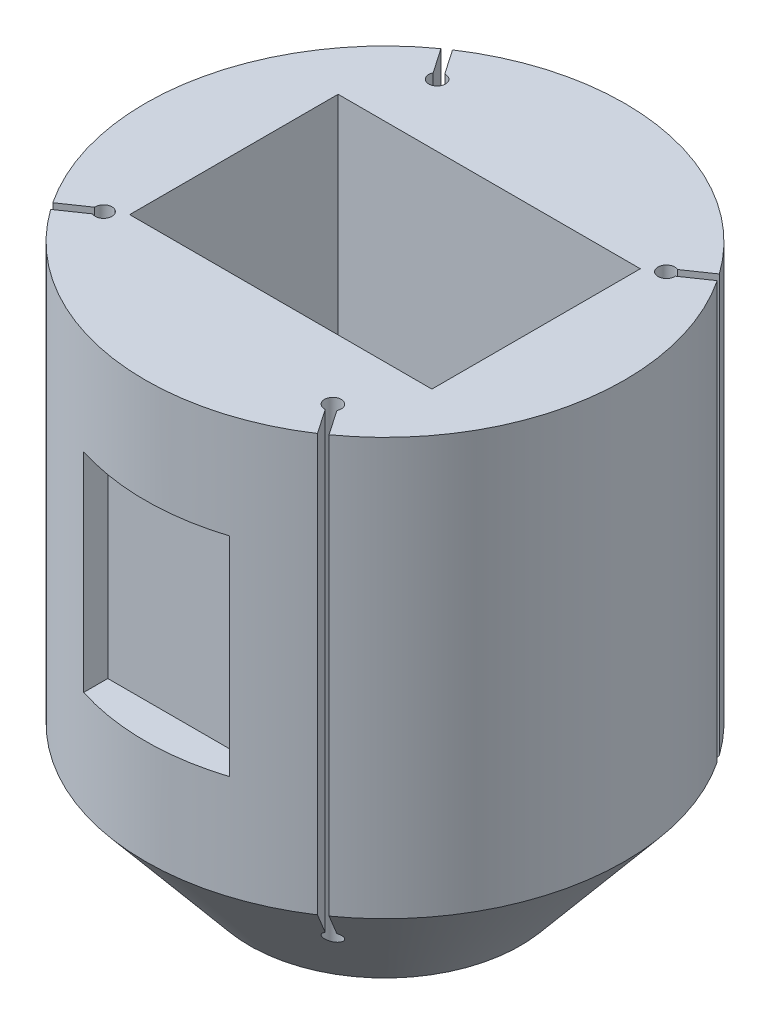
from build123d import *

# Parameters (mm, degrees)
TAGLIO_ESTRUSIONE1_REACH = 262
SCHIZZO3_W               = 145
SCHIZZO3_H               = 100
TAGLIO_ESTRUSIONE2_DEPTH = 100
SCHIZZO4_R               = 4
TAGLIO_ESTRUSIONE3_DEPTH = 250
SCHIZZO6_W               = 70
SCHIZZO6_H               = 100
TAGLIO_ESTRUSIONE4_DEPTH = 18.0000001


with BuildPart() as part:
    # Schizzo1 → Rivoluzione1 (revolve)
    with BuildSketch(Plane.XY, mode=Mode.PRIVATE) as rivoluzione1_sk:
        Polygon((-21.082480081, 47.728392405), (93.917519919, 47.728392405), (93.917519919, -152.271607595), (43.917519919, -212.271607595), (-21.082480081, -212.271607595), align=None)
    revolve(rivoluzione1_sk.sketch.rotate(Axis((-21.082480081, 47.728392405, 0), (0, -1, 0)), 180), axis=Axis((-21.082480081, 47.728392405, 0), (0, -1, 0)))  # turned: the seam where the file's is

    # Taglio-Estrusione1: up to this cone (the profile starts inside it)
    taglio_estrusione1_end = Plane(origin=(-21.082480081, 47.728392, 0), z_dir=(0, 1, 0)).offset(-337.999998595) * Cone(1e-06, 735.13888827, 882.166664924, align=(Align.CENTER, Align.CENTER, Align.MIN), mode=Mode.PRIVATE)
    # Schizzo2 → Taglio-Estrusione1 (cut, up to the surface)
    with BuildSketch(Plane(origin=(0, 47.728392405, 0), x_dir=(1, 0, 0), z_dir=(0, 1, 0)), mode=Mode.PRIVATE) as taglio_estrusione1_sk1:
        with BuildLine():
            Line((60.639027234, 58.610597259), (72.534951309, 66.78904506))
            ThreePointArc((72.534951309, 66.78904506), (73.682341202, 65.150814632), (74.8010666, 63.492877363))
            Line((74.8010666, 63.492877363), (62.905142526, 55.314429562))
            ThreePointArc((62.905142526, 55.314429562), (55.621352222, 52.733884708), (60.639027234, 58.610597259))
        make_face()
    taglio_estrusione1_tool1 = extrude(taglio_estrusione1_sk1.sketch, amount=-TAGLIO_ESTRUSIONE1_REACH, mode=Mode.PRIVATE) & taglio_estrusione1_end
    add(taglio_estrusione1_tool1.solids().sort_by_distance((63.650663, 47.728392, -58.254036))[0], mode=Mode.SUBTRACT)
    # Schizzo2 → Taglio-Estrusione1 (cut, up to the surface)
    with BuildSketch(Plane(origin=(0, 47.728392405, 0), x_dir=(1, 0, 0), z_dir=(0, 1, 0)), mode=Mode.PRIVATE) as taglio_estrusione1_sk2:
        with BuildLine():
            Line((37.528117178, -81.721507315), (45.706564979, -93.617431389))
            ThreePointArc((45.706564979, -93.617431389), (44.068334551, -94.764821283), (42.410397283, -95.883546681))
            Line((42.410397283, -95.883546681), (34.231949481, -83.987622606))
            ThreePointArc((34.231949481, -83.987622606), (31.651404628, -76.703832303), (37.528117178, -81.721507315))
        make_face()
    taglio_estrusione1_tool2 = extrude(taglio_estrusione1_sk2.sketch, amount=-TAGLIO_ESTRUSIONE1_REACH, mode=Mode.PRIVATE) & taglio_estrusione1_end
    add(taglio_estrusione1_tool2.solids().sort_by_distance((37.171556, 47.728392, 84.733143))[0], mode=Mode.SUBTRACT)
    # Schizzo2 → Taglio-Estrusione1 (cut, up to the surface)
    with BuildSketch(Plane(origin=(0, 47.728392405, 0), x_dir=(1, 0, 0), z_dir=(0, 1, 0)), mode=Mode.PRIVATE) as taglio_estrusione1_sk3:
        with BuildLine():
            Line((-102.803987396, -58.610597259), (-114.69991147, -66.78904506))
            ThreePointArc((-114.69991147, -66.78904506), (-115.847301364, -65.150814632), (-116.966026762, -63.492877363))
            Line((-116.966026762, -63.492877363), (-105.070102687, -55.314429562))
            ThreePointArc((-105.070102687, -55.314429562), (-97.786312384, -52.733884708), (-102.803987396, -58.610597259))
        make_face()
    taglio_estrusione1_tool3 = extrude(taglio_estrusione1_sk3.sketch, amount=-TAGLIO_ESTRUSIONE1_REACH, mode=Mode.PRIVATE) & taglio_estrusione1_end
    add(taglio_estrusione1_tool3.solids().sort_by_distance((-105.815623, 47.728392, 58.254036))[0], mode=Mode.SUBTRACT)
    # Schizzo2 → Taglio-Estrusione1 (cut, up to the surface)
    with BuildSketch(Plane(origin=(0, 47.728392405, 0), x_dir=(1, 0, 0), z_dir=(0, 1, 0)), mode=Mode.PRIVATE) as taglio_estrusione1_sk4:
        with BuildLine():
            Line((-79.69307734, 81.721507315), (-87.871525141, 93.617431389))
            ThreePointArc((-87.871525141, 93.617431389), (-86.233294713, 94.764821283), (-84.575357444, 95.883546681))
            Line((-84.575357444, 95.883546681), (-76.396909643, 83.987622606))
            ThreePointArc((-76.396909643, 83.987622606), (-73.816364789, 76.703832303), (-79.69307734, 81.721507315))
        make_face()
    taglio_estrusione1_tool4 = extrude(taglio_estrusione1_sk4.sketch, amount=-TAGLIO_ESTRUSIONE1_REACH, mode=Mode.PRIVATE) & taglio_estrusione1_end
    add(taglio_estrusione1_tool4.solids().sort_by_distance((-79.336516, 47.728392, -84.733143))[0], mode=Mode.SUBTRACT)

    # Schizzo3 → Taglio-Estrusione2 (cut)
    with BuildSketch(Plane(origin=(0, 47.728392405, 0), x_dir=(1, 0, 0), z_dir=(0, 1, 0))):
        with Locations((-21.082480081, 0)):
            Rectangle(SCHIZZO3_W, SCHIZZO3_H)
    extrude(amount=-TAGLIO_ESTRUSIONE2_DEPTH, mode=Mode.SUBTRACT)

    # Schizzo4 → Taglio-Estrusione3 (cut)
    with BuildSketch(Plane(origin=(0, 47.728392405, 0), x_dir=(1, 0, 0), z_dir=(0, 1, 0))):
        with Locations(Location((-71.082480081, 0, 0), (0, 0, 180))):  # turned: the seam where the file's is
            Circle(SCHIZZO4_R)
        with Locations(Location((28.917519919, 0, 0), (0, 0, 180))):  # turned: the seam where the file's is
            Circle(SCHIZZO4_R)
    extrude(amount=-TAGLIO_ESTRUSIONE3_DEPTH, mode=Mode.SUBTRACT)

    # Schizzo6 → Taglio-Estrusione4 (cut, through all)
    with BuildSketch(Plane.XY.offset(98)):
        with Locations((-21.082480081, -52.271607595)):
            Rectangle(SCHIZZO6_W, SCHIZZO6_H)
    extrude(amount=TAGLIO_ESTRUSIONE4_DEPTH, mode=Mode.SUBTRACT)


solid = part.part
